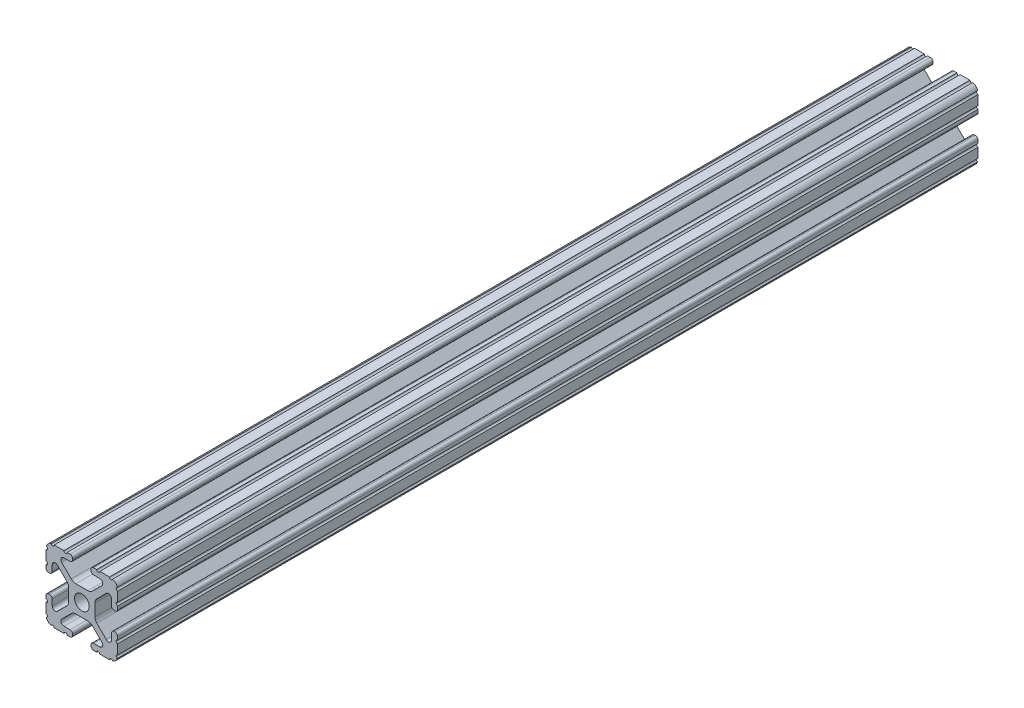
from build123d import *

# Parameters (mm, degrees)
BOSS_EXTRUDE1_DEPTH     = 152.4
SKETCH5_R               = 0.55245
CUT_EXTRUDE1_DEPTH      = 153.4
CUT_EXTRUDE1_DEPTH_BACK = 153.4


with BuildPart() as part:
    # Sketch4 → Boss-Extrude1 (new body, symmetric)
    with BuildSketch(Plane.XY):
        with BuildLine():
            Line((4.190365, -12.7), (10.11729625, -12.7))
            ThreePointArc((10.11729625, -12.7), (11.943543585, -11.943543585), (12.7, -10.11729625))
            Line((12.7, -10.11729625), (12.7, -4.190365))
            ThreePointArc((12.7, -4.190365), (12.42492494, -3.52627506), (11.760835, -3.2512))
            Line((11.760835, -3.2512), (11.429365, -3.2512))
            ThreePointArc((11.429365, -3.2512), (10.76527506, -3.52627506), (10.4902, -4.190365))
            Line((10.4902, -4.190365), (10.4902, -6.348478019))
            ThreePointArc((10.4902, -6.348478019), (9.830707141, -7.335478831), (8.666460301, -7.103895736))
            Line((8.666460301, -7.103895736), (5.299899128, -3.737334563))
            ThreePointArc((5.299899128, -3.737334563), (4.817571085, -3.015479634), (4.6482, -2.16399369))
            Line((4.6482, -2.16399369), (4.6482, 0))
            Line((4.6482, 0), (2.6035, 0))
            ThreePointArc((2.6035, 0), (1.840952505, -1.840952505), (0, -2.6035))
            Line((0, -2.6035), (0, -4.6482))
            Line((0, -4.6482), (2.16399369, -4.6482))
            ThreePointArc((2.16399369, -4.6482), (3.015479634, -4.817571085), (3.737334563, -5.299899128))
            Line((3.737334563, -5.299899128), (7.103895736, -8.666460301))
            ThreePointArc((7.103895736, -8.666460301), (7.335478831, -9.830707141), (6.348478019, -10.4902))
            Line((6.348478019, -10.4902), (4.190365, -10.4902))
            ThreePointArc((4.190365, -10.4902), (3.52627506, -10.76527506), (3.2512, -11.429365))
            Line((3.2512, -11.429365), (3.2512, -11.760835))
            ThreePointArc((3.2512, -11.760835), (3.52627506, -12.42492494), (4.190365, -12.7))
        make_face()
    extrude(amount=BOSS_EXTRUDE1_DEPTH, both=True)

    # Sketch5 → Cut-Extrude1 (cut, two sides)
    with BuildSketch(Plane.XY) as cut_extrude1_sk:
        with Locations((10.356153152, -12.7)):
            Circle(SKETCH5_R)
        with Locations((5.796028019, -12.7)):
            Circle(SKETCH5_R)
        with Locations((12.7, -10.356153152)):
            Circle(SKETCH5_R)
        with Locations((12.7, -5.796028019)):
            Circle(SKETCH5_R)
    extrude(amount=CUT_EXTRUDE1_DEPTH, mode=Mode.SUBTRACT)
    extrude(cut_extrude1_sk.sketch, amount=-CUT_EXTRUDE1_DEPTH_BACK, mode=Mode.SUBTRACT)

    # Mirror1: part across plane


with BuildPart() as part_1:
    add(part.part)
    add(part.part.mirror(Plane(origin=(0, 0, 0), x_dir=(0, 0, 1), z_dir=(1, 0, 0))))

    # Mirror2: part across plane


with BuildPart() as part_2:
    add(part_1.part)
    add(part_1.part.mirror(Plane.ZX))


solid = part_2.part
